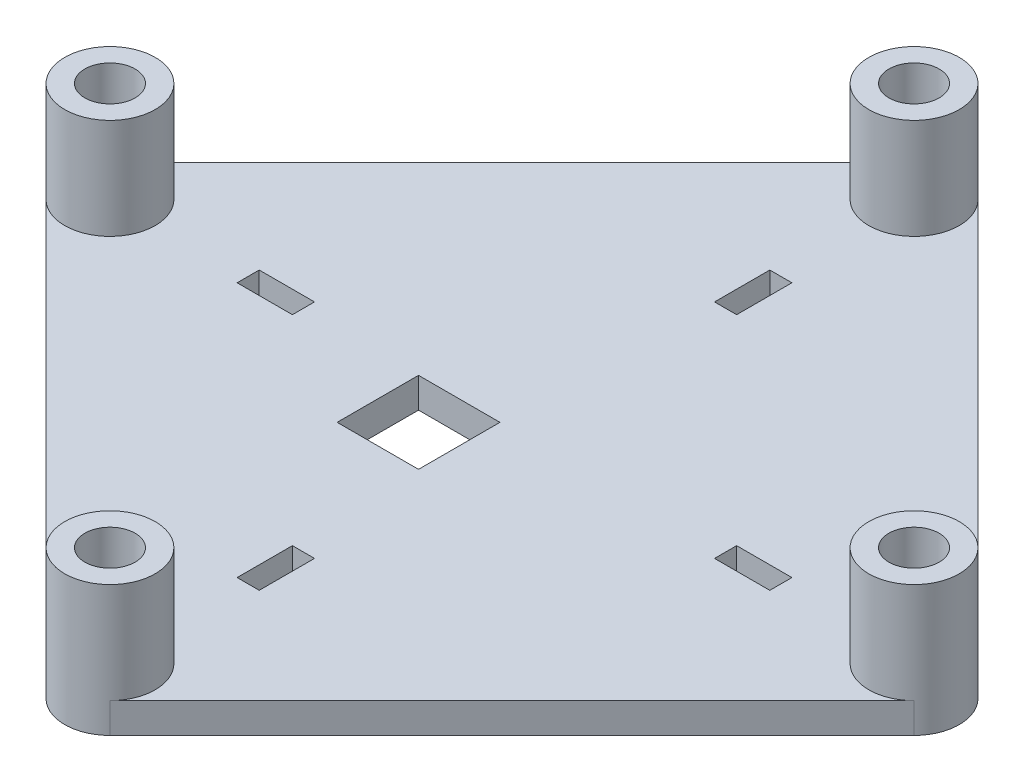
from build123d import *
from build123d.topology import SkipClean

# Parameters (mm, degrees)
SKETCH1_W           = 100
SKETCH1_H           = 100
BOSS_EXTRUDE1_DEPTH = 3
SKETCH2_R           = 4.5
SKETCH2_R_2         = 2.5
BOSS_EXTRUDE2_DEPTH = 10
SKETCH9_OUTSIDE_W   = 130.404
SKETCH9_OUTSIDE_H   = 130.404
CUT_EXTRUDE5_DEPTH  = 127
SKETCH11_W          = 8.1
SKETCH11_H          = 8.1
CUT_EXTRUDE6_DEPTH  = 127
SKETCH3_W           = 5.499999922
SKETCH3_H           = 2.2
SKETCH3_W_2         = 2.2
SKETCH3_H_2         = 5.499999922
CUT_EXTRUDE7_DEPTH  = 64.722052698


with BuildPart() as part:
    # Sketch1 → Boss-Extrude1 (new body)
    with BuildSketch(Plane(origin=(0, 0, 0), x_dir=(1, 0, 0), z_dir=(0, 1, 0))):
        Rectangle(SKETCH1_W, SKETCH1_H)
    extrude(amount=BOSS_EXTRUDE1_DEPTH)

    # Sketch2 → Boss-Extrude2 (add)
    # profile 1 of 4: a face of its own
    with BuildSketch(Plane(origin=(0, 3, 0), x_dir=(1, 0, 0), z_dir=(0, 1, 0))):
        with Locations((0, 40)):
            Circle(SKETCH2_R)
        with Locations((0, 40)):
            Circle(SKETCH2_R_2, mode=Mode.SUBTRACT)
    # profile 2 of 4: a face of its own
    with BuildSketch(Plane(origin=(0, 3, 0), x_dir=(1, 0, 0), z_dir=(0, 1, 0))):
        with Locations((40, 0)):
            Circle(SKETCH2_R)
        with Locations((40, 0)):
            Circle(SKETCH2_R_2, mode=Mode.SUBTRACT)
    # profile 3 of 4: a face of its own
    with BuildSketch(Plane(origin=(0, 3, 0), x_dir=(1, 0, 0), z_dir=(0, 1, 0))):
        with Locations((0, -40)):
            Circle(SKETCH2_R)
        with Locations((0, -40)):
            Circle(SKETCH2_R_2, mode=Mode.SUBTRACT)
    # profile 4 of 4: a face of its own
    with BuildSketch(Plane(origin=(0, 3, 0), x_dir=(1, 0, 0), z_dir=(0, 1, 0))):
        with Locations((-40, 0)):
            Circle(SKETCH2_R)
        with Locations((-40, 0)):
            Circle(SKETCH2_R_2, mode=Mode.SUBTRACT)
    extrude(amount=BOSS_EXTRUDE2_DEPTH)

    # Sketch9 outside → Cut-Extrude5 (cut)
    with BuildSketch(Plane(origin=(0, 3, 0), x_dir=(1, 0, 0), z_dir=(0, 1, 0))):
        Rectangle(SKETCH9_OUTSIDE_W, SKETCH9_OUTSIDE_H)
        with BuildLine():
            Line((3.181980515, 43.181980515), (43.181980515, 3.181980515))
            ThreePointArc((43.181980515, 3.181980515), (44.5, 0), (43.181980515, -3.181980515))
            Line((43.181980515, -3.181980515), (3.181980515, -43.181980515))
            ThreePointArc((3.181980515, -43.181980515), (0, -44.5), (-3.181980515, -43.181980515))
            Line((-3.181980515, -43.181980515), (-43.181980515, -3.181980515))
            ThreePointArc((-43.181980515, -3.181980515), (-44.5, 0), (-43.181980515, 3.181980515))
            Line((-43.181980515, 3.181980515), (-3.181980515, 43.181980515))
            ThreePointArc((-3.181980515, 43.181980515), (0, 44.5), (3.181980515, 43.181980515))
        make_face(mode=Mode.SUBTRACT)
    extrude(amount=-CUT_EXTRUDE5_DEPTH, mode=Mode.SUBTRACT)

    # Sketch11 → Cut-Extrude6 (cut)
    with SkipClean():  # the faces are left unmerged after this step: merging them gives an invalid solid
        with BuildSketch(Plane(origin=(0, 3, 0), x_dir=(1, 0, 0), z_dir=(0, 1, 0))):
            with Locations((-5.45, -3.85)):
                Rectangle(SKETCH11_W, SKETCH11_H)
        extrude(amount=-CUT_EXTRUDE6_DEPTH, mode=Mode.SUBTRACT)

    # Sketch3 → Cut-Extrude7 (cut, through all)
    with SkipClean():  # the faces are left unmerged after this step: merging them gives an invalid solid
        with BuildSketch(Plane(origin=(0, 3, 0), x_dir=(1, 0, 0), z_dir=(0, 1, 0))):
            with Locations((23.749999998, 0.250000008)):
                Rectangle(SKETCH3_W, SKETCH3_H)
            with Locations((0, 24.000000006)):
                Rectangle(SKETCH3_W_2, SKETCH3_H_2)
            with Locations((0, -23.49999999)):
                Rectangle(SKETCH3_W_2, SKETCH3_H_2)
            with Locations((-23.749999998, 0.250000008)):
                Rectangle(SKETCH3_W, SKETCH3_H)
        extrude(amount=-CUT_EXTRUDE7_DEPTH, mode=Mode.SUBTRACT)


solid = part.part
